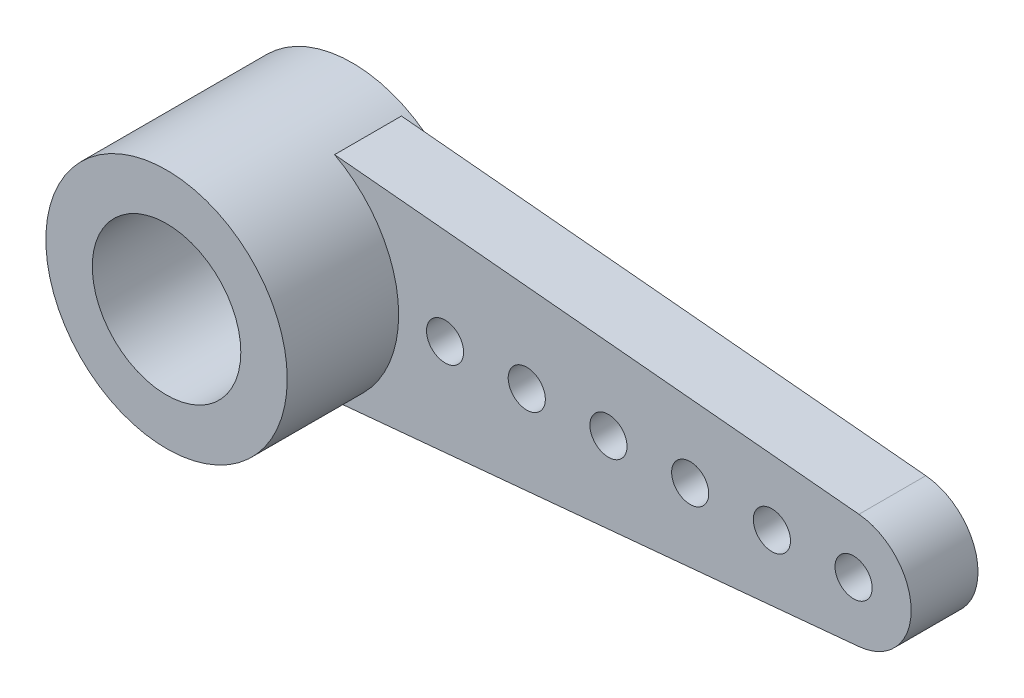
from build123d import *

# Parameters (mm, degrees)
BOSS_EXTRUDE1_DEPTH = 1.8
SKETCH2_R           = 3.25
SKETCH2_R_2         = 2.5
BOSS_EXTRUDE3_DEPTH = 0.2
SKETCH5_R           = 3.25
SKETCH5_R_2         = 2
BOSS_EXTRUDE4_DEPTH = 3
CUT_EXTRUDE1_REACH  = 6.8
SKETCH6_R           = 1.5
CUT_EXTRUDE2_REACH  = 6.8
SKETCH8_R           = 0.5


with BuildPart() as part:
    # Sketch1 → Boss-Extrude1 (new body)
    with BuildSketch(Plane.XY):
        with BuildLine():
            Line((1.525163579, 2.869908719), (15.645, 1.543202838))
            ThreePointArc((15.645, 1.543202838), (17.05, 0), (15.645, -1.543202838))
            Line((15.645, -1.543202838), (1.525163579, -2.869908719))
            ThreePointArc((1.525163579, -2.869908719), (-3.25, 0), (1.525163579, 2.869908719))
        make_face()
    extrude(amount=BOSS_EXTRUDE1_DEPTH)

    # Sketch2 → Boss-Extrude3 (add)
    with BuildSketch(Plane.XY):
        Circle(SKETCH2_R)
        Circle(SKETCH2_R_2, mode=Mode.SUBTRACT)
    extrude(amount=-BOSS_EXTRUDE3_DEPTH)

    # Sketch5 → Boss-Extrude4 (add)
    with BuildSketch(Plane.XY.offset(1.8)):
        Circle(SKETCH5_R)
        Circle(SKETCH5_R_2, mode=Mode.SUBTRACT)
    extrude(amount=BOSS_EXTRUDE4_DEPTH)

    # Sketch6 → Cut-Extrude1 (cut, up to next)
    with BuildSketch(Plane.XY, mode=Mode.PRIVATE) as cut_extrude1_sk1:
        Circle(SKETCH6_R)
    cut_extrude1_tool1 = extrude(cut_extrude1_sk1.sketch, amount=CUT_EXTRUDE1_REACH, mode=Mode.PRIVATE) & part.part
    add(cut_extrude1_tool1.solids().sort_by_distance((0, 0, 0))[0], mode=Mode.SUBTRACT)

    # Sketch8 → Cut-Extrude2 (cut, up to next)
    with BuildSketch(Plane.XY, mode=Mode.PRIVATE) as cut_extrude2_sk1:
        with Locations((15.5, 0)):
            Circle(SKETCH8_R)
    cut_extrude2_tool1 = extrude(cut_extrude2_sk1.sketch, amount=CUT_EXTRUDE2_REACH, mode=Mode.PRIVATE) & part.part
    add(cut_extrude2_tool1.solids().sort_by_distance((15.5, 0, 0))[0], mode=Mode.SUBTRACT)
    # Sketch8 → Cut-Extrude2 (cut, up to next)
    with BuildSketch(Plane.XY, mode=Mode.PRIVATE) as cut_extrude2_sk2:
        with Locations((13.3, 0)):
            Circle(SKETCH8_R)
    cut_extrude2_tool2 = extrude(cut_extrude2_sk2.sketch, amount=CUT_EXTRUDE2_REACH, mode=Mode.PRIVATE) & part.part
    add(cut_extrude2_tool2.solids().sort_by_distance((13.3, 0, 0))[0], mode=Mode.SUBTRACT)
    # Sketch8 → Cut-Extrude2 (cut, up to next)
    with BuildSketch(Plane.XY, mode=Mode.PRIVATE) as cut_extrude2_sk3:
        with Locations((11.1, 0)):
            Circle(SKETCH8_R)
    cut_extrude2_tool3 = extrude(cut_extrude2_sk3.sketch, amount=CUT_EXTRUDE2_REACH, mode=Mode.PRIVATE) & part.part
    add(cut_extrude2_tool3.solids().sort_by_distance((11.1, 0, 0))[0], mode=Mode.SUBTRACT)
    # Sketch8 → Cut-Extrude2 (cut, up to next)
    with BuildSketch(Plane.XY, mode=Mode.PRIVATE) as cut_extrude2_sk4:
        with Locations((8.9, 0)):
            Circle(SKETCH8_R)
    cut_extrude2_tool4 = extrude(cut_extrude2_sk4.sketch, amount=CUT_EXTRUDE2_REACH, mode=Mode.PRIVATE) & part.part
    add(cut_extrude2_tool4.solids().sort_by_distance((8.9, 0, 0))[0], mode=Mode.SUBTRACT)
    # Sketch8 → Cut-Extrude2 (cut, up to next)
    with BuildSketch(Plane.XY, mode=Mode.PRIVATE) as cut_extrude2_sk5:
        with Locations((6.7, 0)):
            Circle(SKETCH8_R)
    cut_extrude2_tool5 = extrude(cut_extrude2_sk5.sketch, amount=CUT_EXTRUDE2_REACH, mode=Mode.PRIVATE) & part.part
    add(cut_extrude2_tool5.solids().sort_by_distance((6.7, 0, 0))[0], mode=Mode.SUBTRACT)
    # Sketch8 → Cut-Extrude2 (cut, up to next)
    with BuildSketch(Plane.XY, mode=Mode.PRIVATE) as cut_extrude2_sk6:
        with Locations((4.5, 0)):
            Circle(SKETCH8_R)
    cut_extrude2_tool6 = extrude(cut_extrude2_sk6.sketch, amount=CUT_EXTRUDE2_REACH, mode=Mode.PRIVATE) & part.part
    add(cut_extrude2_tool6.solids().sort_by_distance((4.5, 0, 0))[0], mode=Mode.SUBTRACT)


solid = part.part
